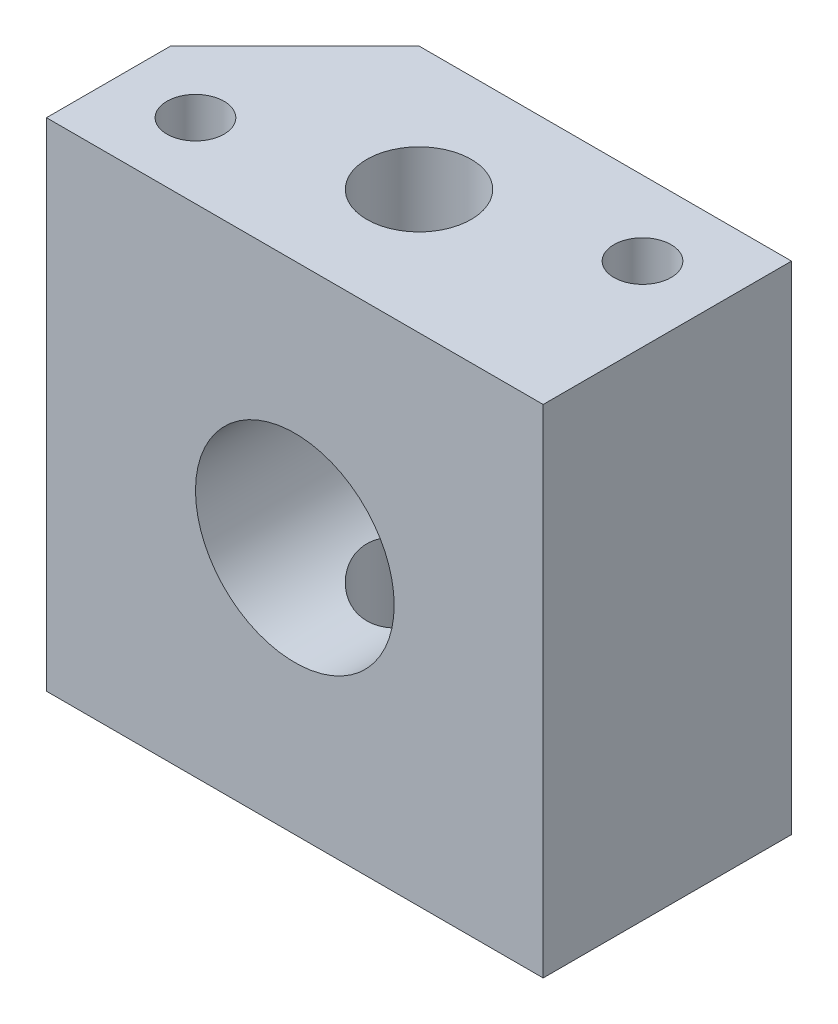
from build123d import *

# Parameters (mm, degrees)
SKETCH1_W           = 20
SKETCH1_H           = 20
SKETCH1_R           = 4
BOSS_EXTRUDE1_DEPTH = 10
SKETCH2_R           = 1.15
SKETCH2_R_2         = 2.1
CUT_EXTRUDE1_DEPTH  = 21
CHAMFER1_SIZE       = 5


with BuildPart() as part:
    # Sketch1 → Boss-Extrude1 (new body)
    with BuildSketch(Plane.XY):
        with Locations((10, 10)):
            Rectangle(SKETCH1_W, SKETCH1_H)
        with Locations((10, 10)):
            Circle(SKETCH1_R, mode=Mode.SUBTRACT)
    extrude(amount=BOSS_EXTRUDE1_DEPTH)

    # Sketch2 → Cut-Extrude1 (cut, through all)
    with BuildSketch(Plane(origin=(0, 20, 0), x_dir=(1, 0, 0), z_dir=(0, 1, 0))):
        with Locations((3, -7)):
            Circle(SKETCH2_R)
        with Locations((17, -3)):
            Circle(SKETCH2_R)
        with Locations((10, -5)):
            Circle(SKETCH2_R_2)
    extrude(amount=-CUT_EXTRUDE1_DEPTH, mode=Mode.SUBTRACT)

    # Chamfer1
    chamfer1_edges = [part.edges().sort_by_distance(p)[0] for p in [
        (0, 10, 0),
    ]]
    chamfer(chamfer1_edges, length=CHAMFER1_SIZE)


solid = part.part
